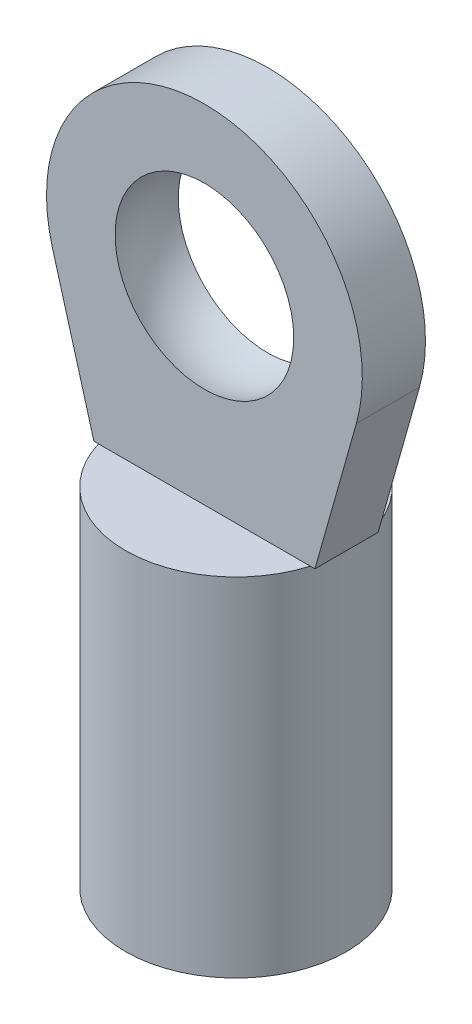
from build123d import *

# Parameters (mm, degrees)
SKETCH1_R                = 3.5
SKETCH1_R_2              = 1.75
BOSS_EXTRUDE1_DEPTH      = 10
SKETCH3_R                = 3.5
BOSS_EXTRUDE2_DEPTH      = 1
BOSS_EXTRUDE3_DEPTH      = 1
BOSS_EXTRUDE3_DEPTH_BACK = 1


with BuildPart() as part:
    # Sketch1 → Boss-Extrude1 (new body)
    with BuildSketch(Plane(origin=(0, 0, 0), x_dir=(1, 0, 0), z_dir=(0, 1, 0))):
        Circle(SKETCH1_R)
        Circle(SKETCH1_R_2, mode=Mode.SUBTRACT)
    extrude(amount=BOSS_EXTRUDE1_DEPTH)

    # Sketch3 → Boss-Extrude2 (add)
    with BuildSketch(Plane(origin=(0, 10, 0), x_dir=(1, 0, 0), z_dir=(0, 1, 0))):
        Circle(SKETCH3_R)
    extrude(amount=BOSS_EXTRUDE2_DEPTH)

    # Sketch2 → Boss-Extrude3 (add, two sides: drawn at the far end of the back side and taken through both)
    with BuildSketch(Plane.XY.offset(-BOSS_EXTRUDE3_DEPTH_BACK)):
        with BuildLine():
            Line((-4.811497646, 15.640040293), (-3.5, 11))
            Line((-3.5, 11), (3.5, 11))
            Line((3.5, 11), (4.811497646, 15.640040293))
            ThreePointArc((4.811497646, 15.640040293), (0, 22), (-4.811497646, 15.640040293))
        make_face()
    extrude(amount=BOSS_EXTRUDE3_DEPTH + BOSS_EXTRUDE3_DEPTH_BACK)

    # Sketch4 → Cut-Revolve1 (revolve, cut)
    with BuildSketch(Plane.XY):
        with BuildLine():
            Line((0, 20), (0, 14))
            ThreePointArc((0, 14), (3, 17), (0, 20))
        make_face()
    revolve(axis=Axis((0, 22, 0), (0, -1, 0)), mode=Mode.SUBTRACT)


solid = part.part
